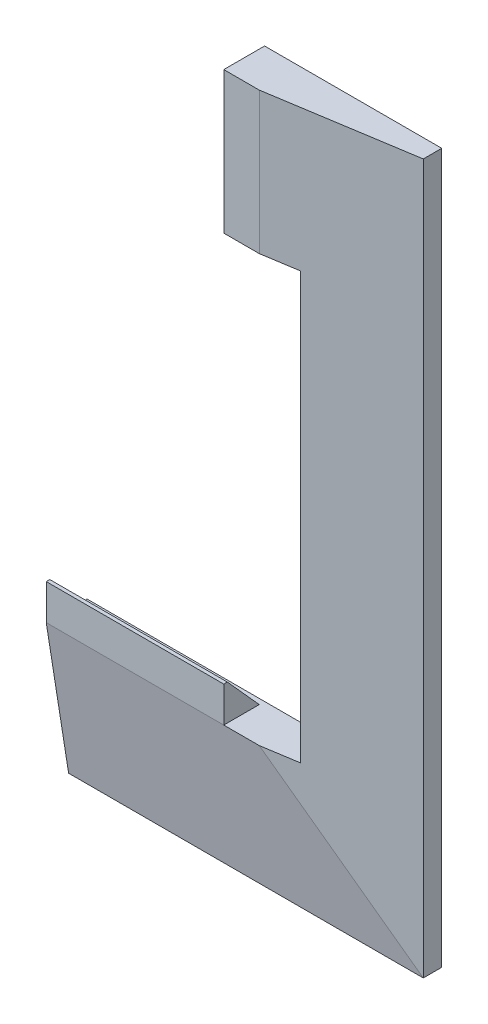
from build123d import *

# Parameters (mm, degrees)
DODANIE_WYCI_GNI_CIE1_DEPTH = 5.2
SZKIC3_W                    = 60
SZKIC3_H                    = 159.9
SZKIC5_W                    = 99.9
SZKIC5_H                    = 199.8
SZKIC6_W                    = 49.271239353
SZKIC6_H                    = 120
WYTNIJ_WYCI_GNI_CIE1_DEPTH  = 78
WYTNIJ_WYCI_GNI_CIE2_DEPTH  = 5.6
SZKIC9_R                    = 2.424871131
SZKIC9_R_2                  = 1.2
DODANIE_WYCI_GNI_CIE3_DEPTH = 3.8
SZKIC10_W                   = 50
SZKIC10_H                   = 39.9
WYTNIJ_WYCI_GNI_CIE4_DEPTH  = 24
DODANIE_WYCI_GNI_CIE4_DEPTH = 50


with BuildPart() as part:
    # Szkic2 → Dodanie-wyciągnięcie1 (new body)
    with BuildSketch(Plane.XY):
        Polygon((18.542832418, 83.245366469), (18.542832418, 43.345366469), (-51.457167582, 43.345366469), (-51.457167582, -76.654633531), (18.542832418, -76.654633531), (18.542832418, -116.554633531), (-81.357167582, -116.554633531), (-81.357167582, 83.245366469), align=None)
    extrude(amount=DODANIE_WYCI_GNI_CIE1_DEPTH)

    # Szkic3 → Wyciągnięcie po profilach3 section 0
    with BuildSketch(Plane.XY.offset(11.5)):
        with Locations((-11.457167582, 3.295366469)):
            Rectangle(SZKIC3_W, SZKIC3_H)
    # Szkic5 → Wyciągnięcie po profilach3 section 1
    with BuildSketch(Plane.XY.offset(5.2)):
        with Locations((-31.407167582, -16.654633531)):
            Rectangle(SZKIC5_W, SZKIC5_H)
    loft()

    # Szkic6 → Wytnij-wyciągnięcie1 (cut)
    with BuildSketch(Plane(origin=(-51.457167582, 0, 0), x_dir=(0, 0, -1), z_dir=(1, 0, 0))):
        with Locations((-24.635619677, -16.654633531)):
            Rectangle(SZKIC6_W, SZKIC6_H)
    extrude(amount=WYTNIJ_WYCI_GNI_CIE1_DEPTH, mode=Mode.SUBTRACT)

    # Szkic7 → Wytnij-wyciągnięcie2 (cut)
    with BuildSketch(Plane(origin=(-51.457167582, 0, 0), x_dir=(0, 0, -1), z_dir=(1, 0, 0))):
        Polygon((-5.12, -34.1297624), (-7.22, -35.342197966), (-7.22, -37.767069096), (-5.12, -38.979504662), (-3.02, -37.767069096), (-3.02, -35.342197966), align=None)
        Polygon((-5.12, 5.6702376), (-7.22, 4.457802034), (-7.22, 2.032930904), (-5.12, 0.820495338), (-3.02, 2.032930904), (-3.02, 4.457802034), align=None)
    extrude(amount=-WYTNIJ_WYCI_GNI_CIE2_DEPTH, mode=Mode.SUBTRACT)

    # Szkic9 → Dodanie-wyciągnięcie3 (add)
    with BuildSketch(Plane(origin=(-51.457167582, 0, 0), x_dir=(0, 0, -1), z_dir=(1, 0, 0))):
        with Locations((-5.12, 3.245366469)):
            Circle(SZKIC9_R)
        with Locations((-5.12, 3.245366469)):
            Circle(SZKIC9_R_2, mode=Mode.SUBTRACT)
        with Locations((-5.12, -36.554633531)):
            Circle(SZKIC9_R)
        with Locations((-5.12, -36.554633531)):
            Circle(SZKIC9_R_2, mode=Mode.SUBTRACT)
    extrude(amount=-DODANIE_WYCI_GNI_CIE3_DEPTH)

    # Szkic10 → Wytnij-wyciągnięcie4 (cut)
    with BuildSketch(Plane.XY.offset(11.5)):
        with Locations((-6.457167582, 63.295366469)):
            Rectangle(SZKIC10_W, SZKIC10_H)
    extrude(amount=-WYTNIJ_WYCI_GNI_CIE4_DEPTH, mode=Mode.SUBTRACT)


with BuildPart() as body_2:
    # Lustro1: mirrored copy
    add(part.part.mirror(Plane(origin=(18.542832418, 83.245366469, 5.2), x_dir=(0, 0, 1), z_dir=(-1, 0, 0))))


with BuildPart() as body_2_1:
    # Obiekt-Przenieś/Kopiuj1: moved
    add(body_2.part.moved(Location((34.890139481, 0, 0))))

    # Szkic11 → Dodanie-wyciągnięcie4 (add)
    with BuildSketch(Plane.ZY.offset(-53.432971899)):
        Polygon((11.5, -76.654633531), (1.5, -76.654633531), (10.5, -66.654633531), (11.5, -66.654633531), align=None)
    extrude(amount=-DODANIE_WYCI_GNI_CIE4_DEPTH)


solid = body_2_1.part
